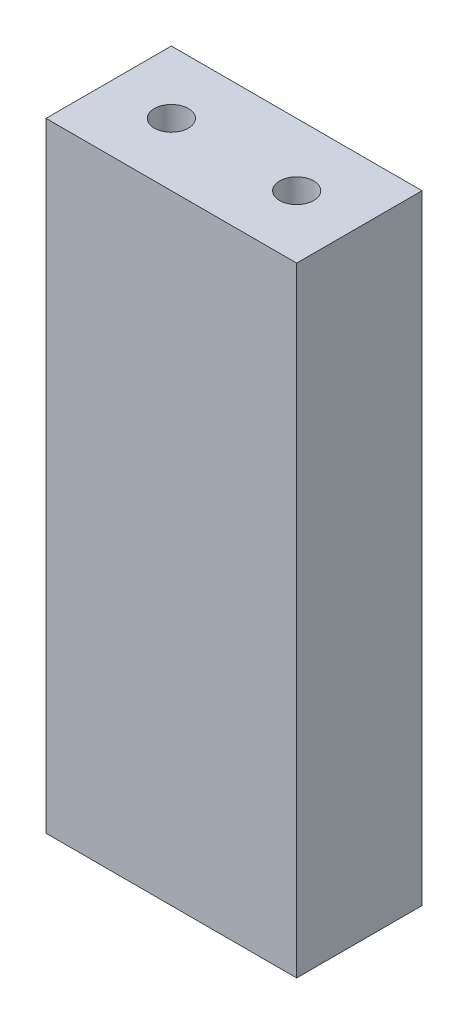
from build123d import *

# Parameters (mm, degrees)
SKETCH1_W                 = 25.4
SKETCH1_H                 = 12.7
BOSS_EXTRUDE1_DEPTH       = 62.738
F_2_56_TAPPED_HOLE1_D     = 1.778
F_2_56_TAPPED_HOLE1_DEPTH = 10.8204
F_2_56_TAPPED_HOLE1_TIP   = 0.53416509
F_8_32_TAPPED_HOLE1_D     = 3.4544
F_8_32_TAPPED_HOLE1_DEPTH = 10.70864
F_8_32_TAPPED_HOLE1_TIP   = 1.037806461


with BuildPart() as part:
    # Sketch1 → Boss-Extrude1 (new body)
    with BuildSketch(Plane(origin=(0, 0, 0), x_dir=(1, 0, 0), z_dir=(0, 1, 0))):
        with Locations((12.7, -6.35)):
            Rectangle(SKETCH1_W, SKETCH1_H)
    extrude(amount=BOSS_EXTRUDE1_DEPTH)

    # #2-56 Tapped Hole1
    with Locations(Plane(origin=(0, 0, 0), x_dir=(-1, 0, 0), z_dir=(0, -1, 0))):
        with Locations((-3.175, -6.35), (-22.225, -6.35)):
            Hole(F_2_56_TAPPED_HOLE1_D / 2, depth=F_2_56_TAPPED_HOLE1_DEPTH)
            with Locations((0, 0, -(F_2_56_TAPPED_HOLE1_DEPTH + F_2_56_TAPPED_HOLE1_TIP / 2))):  # 118° drill point
                Cone(0, F_2_56_TAPPED_HOLE1_D / 2, F_2_56_TAPPED_HOLE1_TIP, mode=Mode.SUBTRACT)

    # #8-32 Tapped Hole1
    with Locations(Plane(origin=(0, 62.738, 0), x_dir=(1, 0, 0), z_dir=(0, 1, 0))):
        with Locations((6.35, -6.35), (19.05, -6.35)):
            Hole(F_8_32_TAPPED_HOLE1_D / 2, depth=F_8_32_TAPPED_HOLE1_DEPTH)
            with Locations((0, 0, -(F_8_32_TAPPED_HOLE1_DEPTH + F_8_32_TAPPED_HOLE1_TIP / 2))):  # 118° drill point
                Cone(0, F_8_32_TAPPED_HOLE1_D / 2, F_8_32_TAPPED_HOLE1_TIP, mode=Mode.SUBTRACT)


solid = part.part
